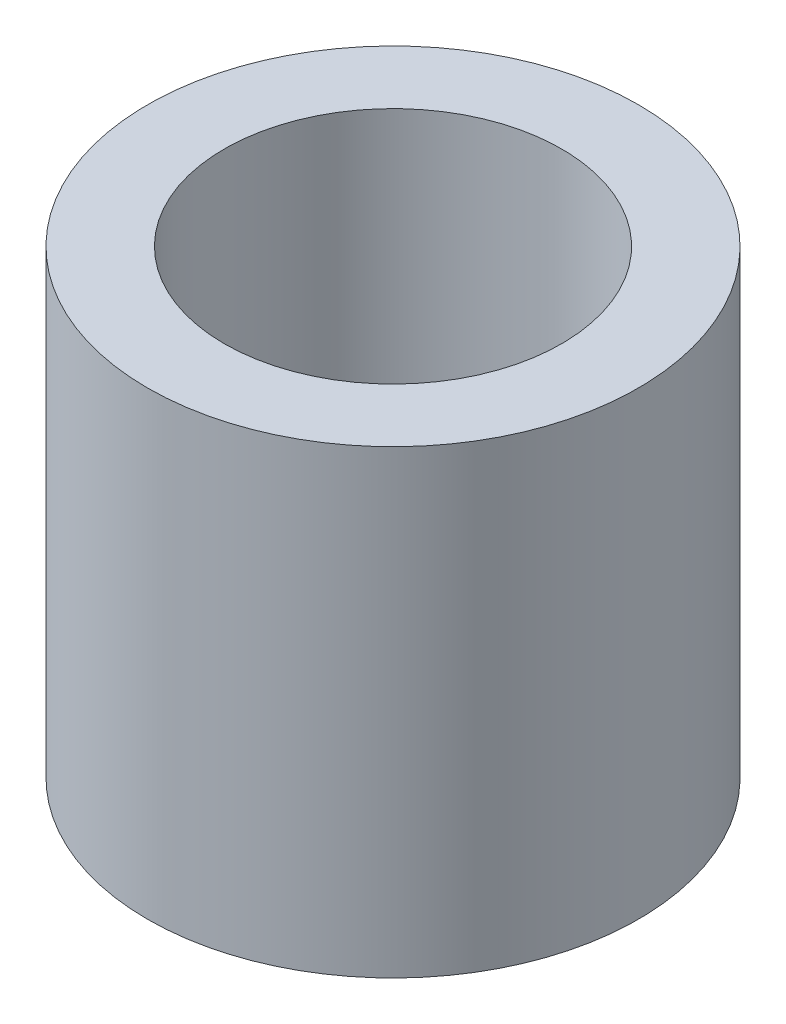
from build123d import *

# Parameters (mm, degrees)
SKETCH1_R           = 4
SKETCH1_R_2         = 2.75
SKETCH1_R_3         = 1.25
BOSS_EXTRUDE1_DEPTH = 2
SKETCH1_3_R         = 4
SKETCH1_3_R_2       = 2.75
BOSS_EXTRUDE2_DEPTH = 7.5


with BuildPart() as part:
    # Sketch1 → Boss-Extrude1 (new body)
    with BuildSketch(Plane(origin=(0, 0, 0), x_dir=(1, 0, 0), z_dir=(0, 1, 0))):
        with Locations(Location((0, 0, 0), (0, 0, 270))):
            Circle(SKETCH1_R)
        Circle(SKETCH1_R_2, mode=Mode.SUBTRACT)
        Circle(SKETCH1_R_2)
        with Locations(Location((0, 0, 0), (0, 0, 270))):
            Circle(SKETCH1_R_3, mode=Mode.SUBTRACT)
    extrude(amount=BOSS_EXTRUDE1_DEPTH)

    # Sketch1_3 → Boss-Extrude2 (add)
    with BuildSketch(Plane(origin=(0, 0, 0), x_dir=(1, 0, 0), z_dir=(0, 1, 0))):
        with Locations(Location((0, 0, 0), (0, 0, 270))):
            Circle(SKETCH1_3_R)
        with Locations(Location((0, 0, 0), (0, 0, 270))):
            Circle(SKETCH1_3_R_2, mode=Mode.SUBTRACT)
    extrude(amount=BOSS_EXTRUDE2_DEPTH)


solid = part.part
